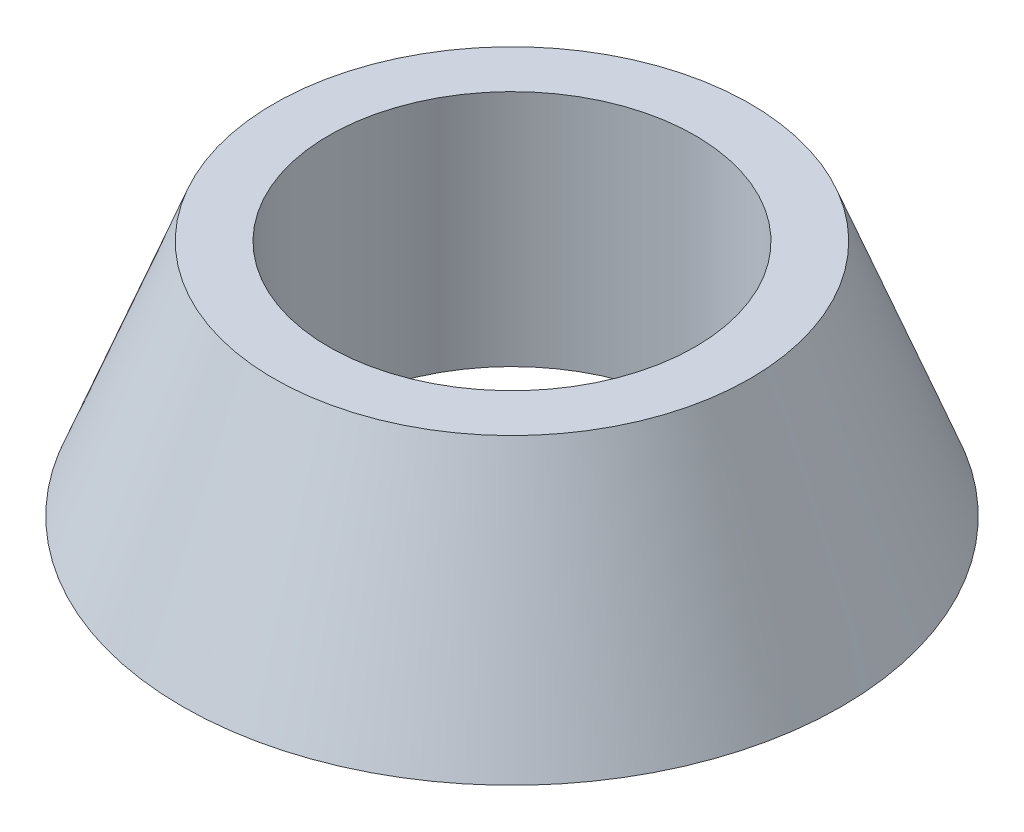
from build123d import *


with BuildPart() as part:
    # Szkic1 → Obrót1 (revolve)
    with BuildSketch(Plane.XY):
        Polygon((5, 0), (5, 6.5), (6.5, 6.5), (9, 0), align=None)
    revolve(axis=Axis((0, 0, 0), (0, 1, 0)))


solid = part.part
